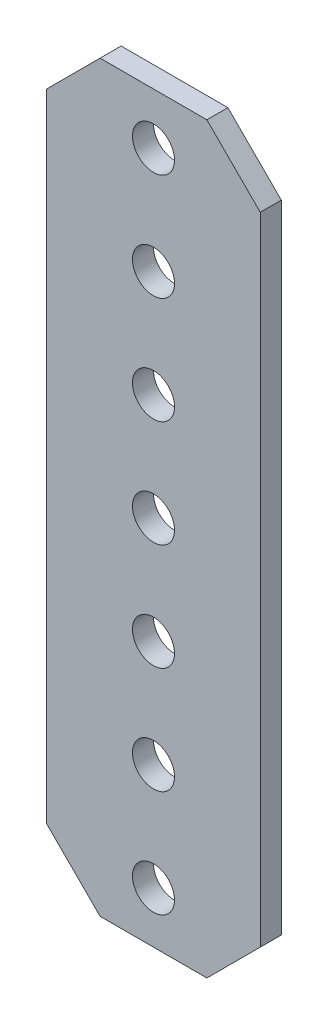
from build123d import *

# Parameters (mm, degrees)
SKETCH1_R           = 2.5
BOSS_EXTRUDE1_DEPTH = 2.5


with BuildPart() as part:
    # Sketch1 → Boss-Extrude1 (new body)
    with BuildSketch(Plane.XY.offset(1.25)):
        Polygon((-12.7, 37.846), (-12.7, -37.846), (-6.35, -44.196), (6.35, -44.196), (12.7, -37.846), (12.7, 37.846), (6.35, 44.196), (-6.35, 44.196), align=None)
        with Locations((0, -38.1)):
            Circle(SKETCH1_R, mode=Mode.SUBTRACT)
        with Locations((0, -25.4)):
            Circle(SKETCH1_R, mode=Mode.SUBTRACT)
        with Locations((0, -12.7)):
            Circle(SKETCH1_R, mode=Mode.SUBTRACT)
        Circle(SKETCH1_R, mode=Mode.SUBTRACT)
        with Locations((0, 12.7)):
            Circle(SKETCH1_R, mode=Mode.SUBTRACT)
        with Locations((0, 38.1)):
            Circle(SKETCH1_R, mode=Mode.SUBTRACT)
        with Locations((0, 25.4)):
            Circle(SKETCH1_R, mode=Mode.SUBTRACT)
    extrude(amount=-BOSS_EXTRUDE1_DEPTH)


solid = part.part
